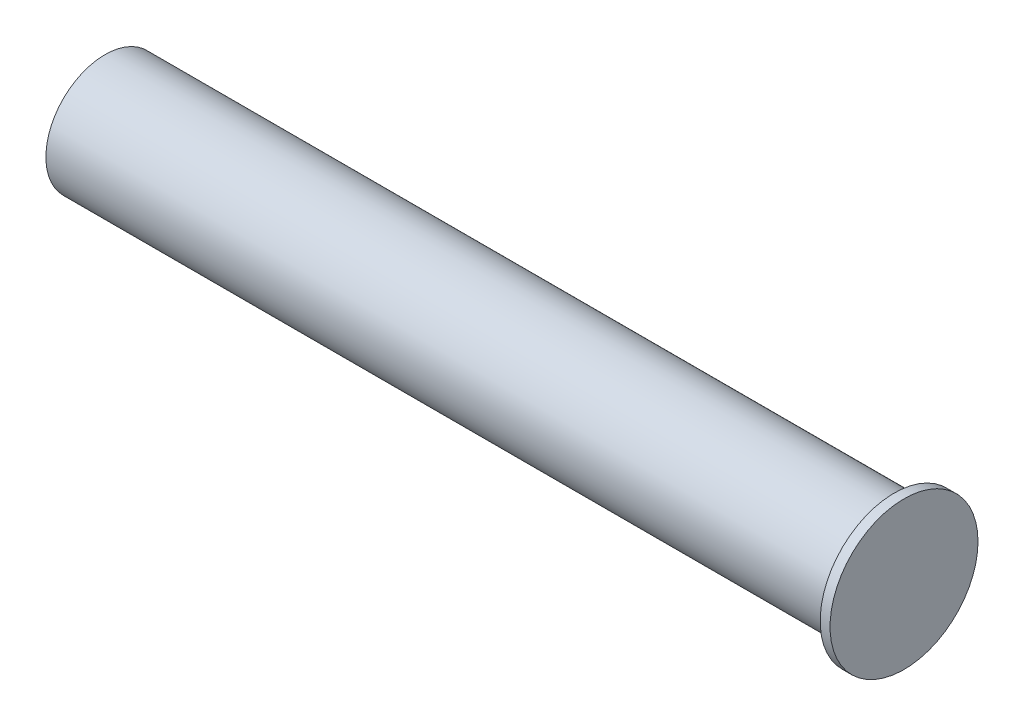
from build123d import *

# Parameters (mm, degrees)
SKETCH1_R           = 6
BOSS_EXTRUDE1_DEPTH = 80
SKETCH2_R           = 7.5
BOSS_EXTRUDE2_DEPTH = 1


with BuildPart() as part:
    # Sketch1 → Boss-Extrude1 (new body)
    with BuildSketch(Plane(origin=(0, 0, 0), x_dir=(0, 0, -1), z_dir=(1, 0, 0))):
        Circle(SKETCH1_R)
    extrude(amount=BOSS_EXTRUDE1_DEPTH)

    # Sketch2 → Boss-Extrude2 (add)
    with BuildSketch(Plane(origin=(80, 0, 0), x_dir=(0, 0, -1), z_dir=(1, 0, 0))):
        Circle(SKETCH2_R)
    extrude(amount=BOSS_EXTRUDE2_DEPTH)


solid = part.part
